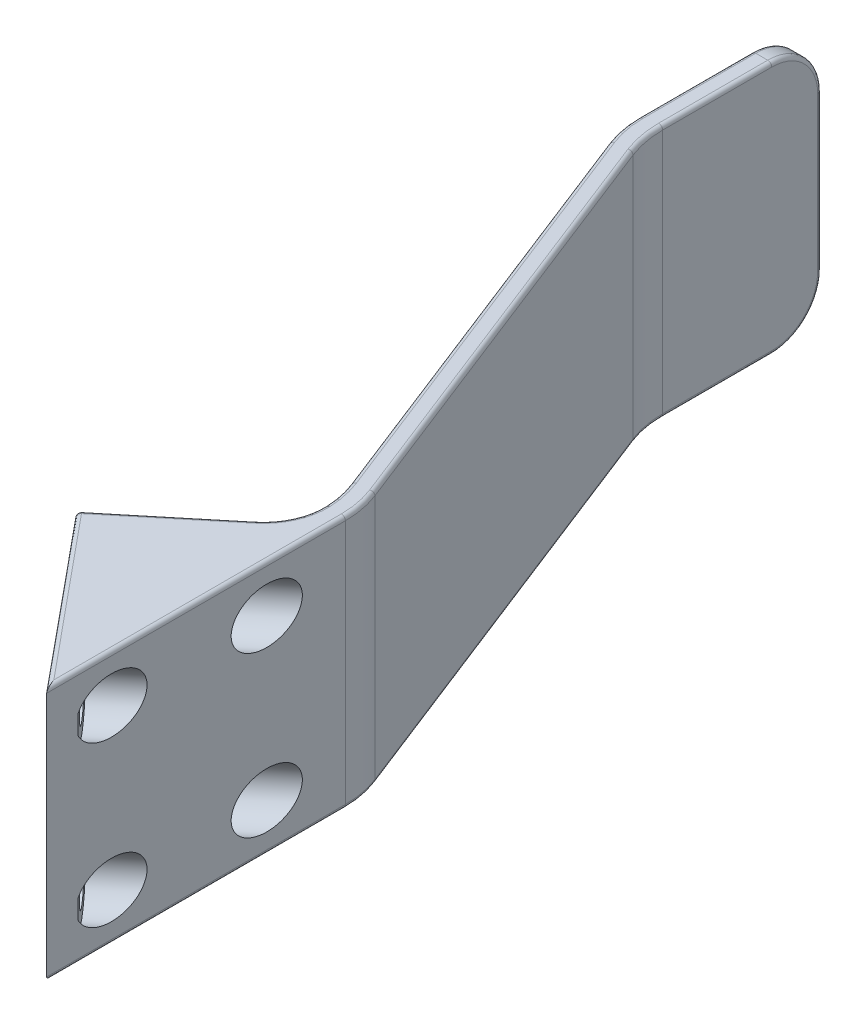
from build123d import *

# Parameters (mm, degrees)
SKETCH1_W           = 2
SKETCH1_H           = 25.4
SKETCH4_W           = 5
SKETCH4_H           = 25.4
CUT_EXTRUDE2_DEPTH  = 21
BOSS_EXTRUDE2_DEPTH = 25.4
BOSS_EXTRUDE4_DEPTH = 25.4
FILLET1_R           = 5
CUT_EXTRUDE3_DEPTH  = 26.4
SKETCH9_R           = 1.6
CUT_EXTRUDE4_DEPTH  = 2
SKETCH10_R          = 2.75
CUT_EXTRUDE5_DEPTH  = 59.842249491
FILLET2_R           = 10
FILLET5_R           = 6
FILLET3_R           = 0.4


with BuildPart() as part:
    # Sweep1: sweep along a path in Sketch2
    with BuildLine(Plane(origin=(0, 0, 0), x_dir=(1, 0, 0), z_dir=(0, 1, 0))) as sweep1_path:
        Line((22, 0), (22, 57.2))
        Line((22, 57.2), (4, 103.2))
        Line((4, 103.2), (4, 121.2))
    # Sketch1 → Sweep1 (sweep)
    with BuildSketch(Plane.XY):
        with Locations((22, 0)):
            Rectangle(SKETCH1_W, SKETCH1_H)
    sweep(path=sweep1_path.line, transition=Transition.RIGHT)

    # Sketch4 → Cut-Extrude2 (cut, through all)
    with BuildSketch(Plane(origin=(23, 0, 0), x_dir=(0, 0, -1), z_dir=(1, 0, 0))):
        with Locations((2.5, 0)):
            Rectangle(SKETCH4_W, SKETCH4_H)
    extrude(amount=-CUT_EXTRUDE2_DEPTH, mode=Mode.SUBTRACT)

    # Sketch5 → Boss-Extrude2 (add, through all)
    with BuildSketch(Plane.XZ.offset(12.7)):
        Polygon((21, -42.561313548), (21, -28.015116906), (9, -42.561313548), align=None)
    extrude(amount=-BOSS_EXTRUDE2_DEPTH)

    # Sketch6 → Boss-Extrude4 (add, through all)
    with BuildSketch(Plane.XZ.offset(12.7)):
        Polygon((9, -42.561313548), (21, -52.460808484), (21, -42.561313548), align=None)
    extrude(amount=-BOSS_EXTRUDE4_DEPTH)

    # Fillet1
    fillet1_edges = [part.edges().sort_by_distance(p)[0] for p in [
        (4, -12.7, -121.2),
        (4, 12.7, -121.2),
    ]]
    fillet(fillet1_edges, radius=FILLET1_R)

    # Sketch8 → Cut-Extrude3 (cut, through all)
    with BuildSketch(Plane.XZ.offset(12.7)):
        Polygon((23, -25.590750799), (23, -5), (21, -5), (21, -28.015116906), align=None)
    extrude(amount=-CUT_EXTRUDE3_DEPTH, mode=Mode.SUBTRACT)

    # Sketch9 → Cut-Extrude4 (cut)
    with BuildSketch(Plane(origin=(26.248041717, 0, -21.653529673), x_dir=(0.636363636, 0, 0.771389216), z_dir=(-0.771389216, 0, 0.636363636))):
        with Locations((-22.104065555, 8)):
            Circle(SKETCH9_R)
        with Locations((-22.104065555, -8)):
            Circle(SKETCH9_R)
        with Locations((-10.104065555, -8)):
            Circle(SKETCH9_R)
        with Locations((-10.104065555, 8)):
            Circle(SKETCH9_R)
    extrude(amount=-CUT_EXTRUDE4_DEPTH, mode=Mode.SUBTRACT)

    # Sketch10 → Cut-Extrude5 (cut, through all)
    with BuildSketch(Plane(origin=(27.790820149, 0, -22.926256946), x_dir=(0.636363636, 0, 0.771389216), z_dir=(-0.771389216, 0, 0.636363636))):
        with Locations((-22.104065555, 8)):
            Circle(SKETCH10_R)
        with Locations((-10.104065555, 8)):
            Circle(SKETCH10_R)
        with Locations((-10.104065555, -8)):
            Circle(SKETCH10_R)
        with Locations((-22.104065555, -8)):
            Circle(SKETCH10_R)
    extrude(amount=-CUT_EXTRUDE5_DEPTH, mode=Mode.SUBTRACT)

    # Fillet2
    fillet2_edges = [part.edges().sort_by_distance(p)[0] for p in [
        (23, 0, -57.388686452),
        (21, 0, -57.011313548),
        (3, 0, -103.011313548),
        (5, 0, -103.388686452),
    ]]
    fillet(fillet2_edges, radius=FILLET2_R)

    # Fillet5
    fillet5_edges = [part.edges().sort_by_distance(p)[0] for p in [
        (21, 0, -52.460808484),
    ]]
    fillet(fillet5_edges, radius=FILLET5_R)

    # Fillet3
    fillet3_edges = [part.edges().sort_by_distance(p)[0] for p in [
        (5, -12.7, -110.737775488),
        (5, 12.7, -110.737775488),
        (14, 12.7, -80.388686452),
        (14, -12.7, -80.388686452),
        (3, -12.7, -110.549089035),
        (3, 12.7, -110.549089035),
        (23, 12.7, -40.546286364),
        (12, 12.7, -80.011313548),
        (22.826603634, 12.7, -57.355968907),
        (3.173396366, 12.7, -103.044031093),
        (12, -12.7, -80.011313548),
        (23, -12.7, -40.546286364),
        (22.826603634, -12.7, -57.355968907),
        (3.173396366, -12.7, -103.044031093),
        (5.173396366, -12.7, -103.421403997),
        (5.173396366, 12.7, -103.421403997),
        (20.787013978, 12.7, -57.177339033),
        (20.787013978, -12.7, -57.177339033),
        (20.474647805, -12.7, -52.838617841),
        (20.474647805, 12.7, -52.838617841),
        (16, 12.7, -34.076032173),
        (9, 0, -42.561313548),
        (16, -12.7, -34.076032173),
        (13.907448432, 12.7, -46.609751957),
        (13.907448432, -12.7, -46.609751957),
        (5, 0, -121.2),
        (5, 11.235533906, -119.735533906),
        (5, -11.235533906, -119.735533906),
        (3, 0, -121.2),
        (3, 11.235533906, -119.735533906),
        (3, -11.235533906, -119.735533906),
    ]]
    fillet(fillet3_edges, radius=FILLET3_R)


solid = part.part
